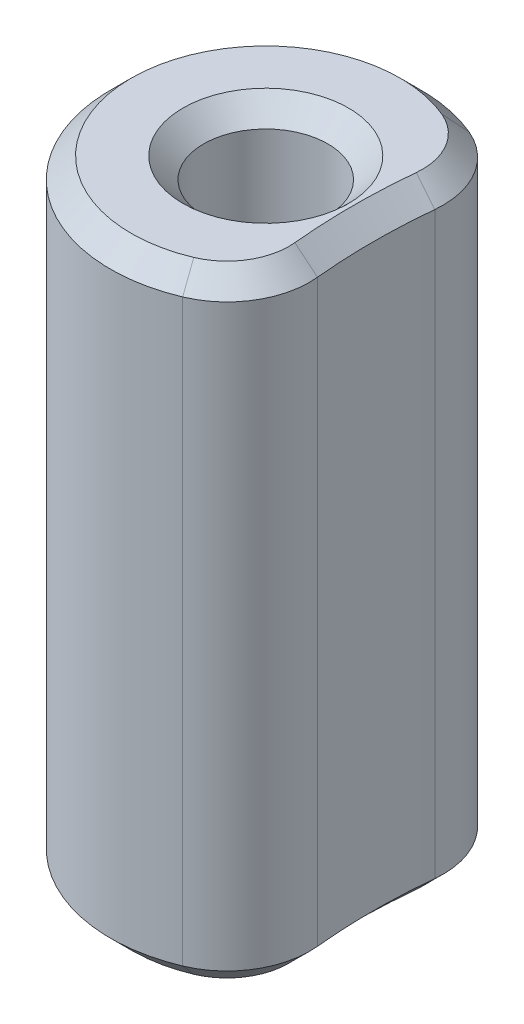
from build123d import *

# Parameters (mm, degrees)
SKETCH1_R           = 1.905
BOSS_EXTRUDE1_DEPTH = 9.525
FILLET1_R           = 2.54
CHAMFER1_SIZE       = 0.635


with BuildPart() as part:
    # Sketch1 → Boss-Extrude1 (new body, symmetric)
    with BuildSketch(Plane(origin=(0, 0, 0), x_dir=(1, 0, 0), z_dir=(0, 1, 0))):
        with BuildLine():
            ThreePointArc((3.572376077, -3.149529395), (3.298614691, 0), (3.572376077, 3.149529395))
            ThreePointArc((3.572376077, 3.149529395), (-4.7625, 0), (3.572376077, -3.149529395))
        make_face()
        Circle(SKETCH1_R, mode=Mode.SUBTRACT)
    extrude(amount=BOSS_EXTRUDE1_DEPTH, both=True)

    # Fillet1
    fillet1_edges = [part.edges().sort_by_distance(p)[0] for p in [
        (3.572376077, 0, -3.149529395),
        (3.572376077, 0, 3.149529395),
    ]]
    fillet(fillet1_edges, radius=FILLET1_R)

    # Chamfer1
    chamfer1_edges = [part.edges().sort_by_distance(p)[0] for p in [
        (-4.7625, -9.525, 0),
        (-4.7625, 9.525, 0),
        (3.298614691, -9.525, 0),
        (3.041807621, -9.525, 3.349691374),
        (3.041807621, -9.525, -3.349691374),
        (3.298614691, 9.525, 0),
        (3.041807621, 9.525, 3.349691374),
        (3.041807621, 9.525, -3.349691374),
        (-1.905, -9.525, 0),
        (-1.905, 9.525, 0),
    ]]
    chamfer(chamfer1_edges, length=CHAMFER1_SIZE)


solid = part.part
